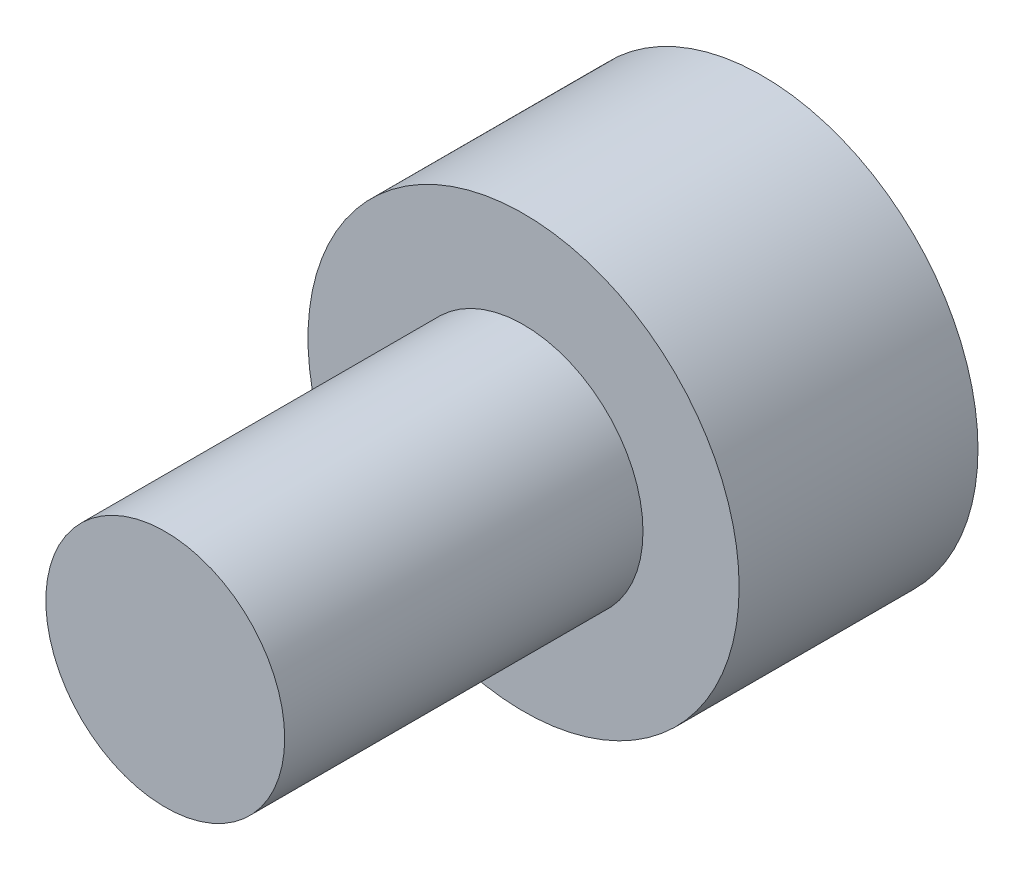
from build123d import *

# Parameters (mm, degrees)
SKETCH1_R           = 3.61
BOSS_EXTRUDE1_DEPTH = 4
SKETCH2_R           = 2
BOSS_EXTRUDE2_DEPTH = 6


with BuildPart() as part:
    # Sketch1 → Boss-Extrude1 (new body)
    with BuildSketch(Plane.XY):
        Circle(SKETCH1_R)
    extrude(amount=BOSS_EXTRUDE1_DEPTH)

    # Sketch2 → Boss-Extrude2 (add)
    with BuildSketch(Plane.XY.offset(4)):
        Circle(SKETCH2_R)
    extrude(amount=BOSS_EXTRUDE2_DEPTH)


solid = part.part
